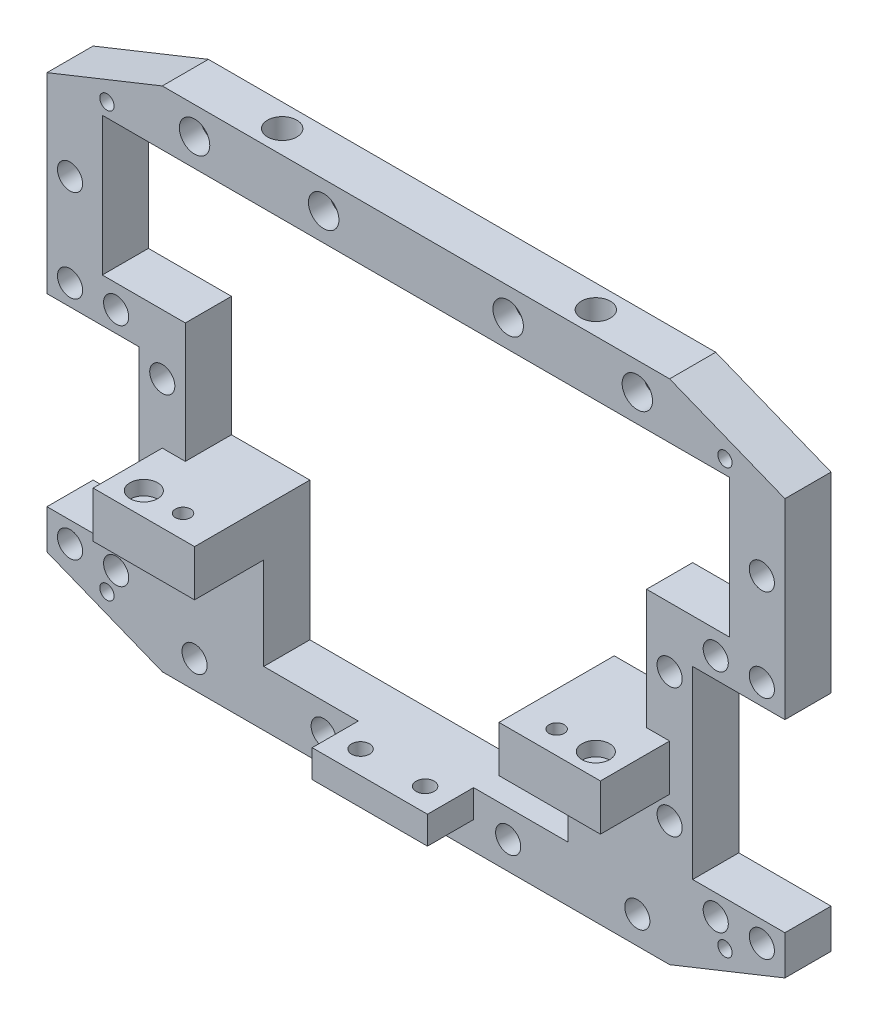
from build123d import *

# Parameters (mm, degrees)
SKETCH1_R                 = 2.725
SKETCH1_R_2               = 2.1
BOSS_EXTRUDE2_DEPTH       = 202.6
SKETCH2_W                 = 182.6
SKETCH2_H                 = 86
CUT_EXTRUDE1_DEPTH        = 161
CUT_EXTRUDE3_START        = 182.6
SKETCH4_R                 = 3
CUT_EXTRUDE3_DEPTH        = 4.5
SKETCH3_W                 = 110
SKETCH3_H                 = 182.6
CUT_EXTRUDE4_DEPTH        = 111
CUT_EXTRUDE5_START        = -12
SKETCH5_W                 = 125
SKETCH5_H                 = 182.6
CUT_EXTRUDE5_DEPTH        = 111
SKETCH6_W                 = 20
SKETCH6_H                 = 40
CUT_EXTRUDE7_DEPTH        = 12
SKETCH8_R                 = 2.725
BOSS_EXTRUDE3_DEPTH       = 10
BOSS_EXTRUDE4_START       = -192.6
SKETCH8_2_R               = 2.725
BOSS_EXTRUDE4_DEPTH       = 10
BOSS_EXTRUDE5_START       = 30
SKETCH9_W                 = 2
SKETCH9_H                 = 10
SKETCH9_W_2               = 15
SKETCH9_H_2               = 5
SKETCH9_R                 = 1.65
BOSS_EXTRUDE5_DEPTH       = 10
SKETCH10_W                = 22
SKETCH10_H                = 10
BOSS_EXTRUDE6_DEPTH       = 20
MIRROR3_START             = 30
MIRROR3_COPY_1_SKETCH_W   = 2
MIRROR3_COPY_1_SKETCH_H   = 10
MIRROR3_COPY_1_SKETCH_W_2 = 15
MIRROR3_COPY_1_SKETCH_H_2 = 5
MIRROR3_COPY_1_SKETCH_R   = 1.65
MIRROR3_COPY_1_DEPTH      = 10
MIRROR3_COPY_2_SKETCH_W   = 22
MIRROR3_COPY_2_SKETCH_H   = 10
MIRROR3_COPY_2_DEPTH      = 20
SKETCH11_R                = 2.25
CUT_EXTRUDE8_DEPTH        = 203.6
SKETCH12_R                = 3
CUT_EXTRUDE9_DEPTH        = 3.1
CUT_EXTRUDE10_DEPTH       = 111
SKETCH14_R                = 1.55
CUT_EXTRUDE11_DEPTH       = 10
SKETCH15_R                = 2.6
CUT_EXTRUDE12_DEPTH       = 5
BOSS_EXTRUDE7_START       = -12
SKETCH16_W                = 25
SKETCH16_H                = 10
SKETCH16_R                = 1.95
BOSS_EXTRUDE7_DEPTH       = 6
SKETCH17_R                = 1.95
CUT_EXTRUDE13_DEPTH       = 5
SKETCH18_R                = 2.725
CUT_EXTRUDE14_DEPTH       = 11
SKETCH19_R                = 3.175
CUT_EXTRUDE15_DEPTH       = 20
SKETCH20_R                = 2.725
CUT_EXTRUDE16_DEPTH       = 20
SKETCH21_R                = 3.3
CUT_EXTRUDE17_DEPTH       = 4.5


with BuildPart() as part:
    # Sketch1 → Boss-Extrude2 (new body)
    with BuildSketch(Plane.XY):
        Polygon((-48.624838984, -50.035732152), (61.375161016, -50.035732152), (86.375161016, -40.035732152), (86.375161016, 49.964267848), (61.375161016, 59.964267848), (-48.624838984, 59.964267848), (-73.624838984, 49.964267848), (-73.624838984, -40.035732152), align=None)
        with Locations((-41.624838984, -44.035732152)):
            Circle(SKETCH1_R, mode=Mode.SUBTRACT)
        with Locations((-68.624838984, -23.035732152)):
            Circle(SKETCH1_R, mode=Mode.SUBTRACT)
        with Locations((-13.624838984, -44.035732152)):
            Circle(SKETCH1_R, mode=Mode.SUBTRACT)
        with Locations((-68.624838984, 4.964267848)):
            Circle(SKETCH1_R, mode=Mode.SUBTRACT)
        with Locations((26.375161016, -44.035732152)):
            Circle(SKETCH1_R, mode=Mode.SUBTRACT)
        with Locations((54.375161016, -44.035732152)):
            Circle(SKETCH1_R, mode=Mode.SUBTRACT)
        with Locations((81.375161016, -23.035732152)):
            Circle(SKETCH1_R, mode=Mode.SUBTRACT)
        Polygon((74.375161016, 47.964267848), (74.375161016, -38.035732152), (13.375161016, -38.035732152), (-0.624838984, -38.035732152), (-61.624838984, -38.035732152), (-61.624838984, 47.964267848), (-7.624838984, 47.964267848), (-0.624838984, 47.964267848), (13.375161016, 47.964267848), (20.375161016, 47.964267848), align=None, mode=Mode.SUBTRACT)
        with Locations((81.375161016, 4.964267848)):
            Circle(SKETCH1_R, mode=Mode.SUBTRACT)
        with Locations((-68.624838984, 32.964267848)):
            Circle(SKETCH1_R, mode=Mode.SUBTRACT)
        with Locations((-41.624838984, 53.964267848)):
            Circle(SKETCH1_R_2, mode=Mode.SUBTRACT)
        with Locations((-13.624838984, 53.964267848)):
            Circle(SKETCH1_R_2, mode=Mode.SUBTRACT)
        with Locations((26.375161016, 53.964267848)):
            Circle(SKETCH1_R_2, mode=Mode.SUBTRACT)
        with Locations((81.375161016, 32.964267848)):
            Circle(SKETCH1_R, mode=Mode.SUBTRACT)
        with Locations((54.375161016, 53.964267848)):
            Circle(SKETCH1_R_2, mode=Mode.SUBTRACT)
    extrude(amount=BOSS_EXTRUDE2_DEPTH)

    # Sketch2 → Cut-Extrude1 (cut, through all)
    with BuildSketch(Plane.ZY.offset(73.624838984)):
        with Locations((101.3, 4.964267848)):
            Rectangle(SKETCH2_W, SKETCH2_H)
    extrude(amount=-CUT_EXTRUDE1_DEPTH, mode=Mode.SUBTRACT)

    # Sketch4 → Cut-Extrude3 (cut)
    with BuildSketch(Plane.XY.offset(10).offset(CUT_EXTRUDE3_START)):
        with Locations((-68.624838984, 32.964267848)):
            Circle(SKETCH4_R)
        with Locations((-68.624838984, 4.964267848)):
            Circle(SKETCH4_R)
        with Locations((-68.624838984, -23.035732152)):
            Circle(SKETCH4_R)
        with Locations((-41.624838984, 53.964267848)):
            Circle(SKETCH4_R)
        with Locations((-13.624838984, 53.964267848)):
            Circle(SKETCH4_R)
        with Locations((26.375161016, 53.964267848)):
            Circle(SKETCH4_R)
        with Locations((54.375161016, 53.964267848)):
            Circle(SKETCH4_R)
        with Locations((81.375161016, 32.964267848)):
            Circle(SKETCH4_R)
        with Locations((81.375161016, 4.964267848)):
            Circle(SKETCH4_R)
        with Locations((81.375161016, -23.035732152)):
            Circle(SKETCH4_R)
        with Locations((54.375161016, -44.035732152)):
            Circle(SKETCH4_R)
        with Locations((26.375161016, -44.035732152)):
            Circle(SKETCH4_R)
        with Locations((-13.624838984, -44.035732152)):
            Circle(SKETCH4_R)
        with Locations((-41.624838984, -44.035732152)):
            Circle(SKETCH4_R)
    extrude(amount=CUT_EXTRUDE3_DEPTH, mode=Mode.SUBTRACT)

    # Sketch3 → Cut-Extrude4 (cut, through all)
    with BuildSketch(Plane(origin=(0, 59.964267848, 0), x_dir=(1, 0, 0), z_dir=(0, 1, 0))):
        with Locations((6.375161016, -101.3)):
            Rectangle(SKETCH3_W, SKETCH3_H)
    extrude(amount=-CUT_EXTRUDE4_DEPTH, mode=Mode.SUBTRACT)

    # Sketch5 → Cut-Extrude5 (cut, through all)
    with BuildSketch(Plane(origin=(0, -38.035732152, 0), x_dir=(1, 0, 0), z_dir=(0, 1, 0)).offset(CUT_EXTRUDE5_START)):
        with Locations((6.375161016, -101.3)):
            Rectangle(SKETCH5_W, SKETCH5_H)
    extrude(amount=CUT_EXTRUDE5_DEPTH, mode=Mode.SUBTRACT)

    # Sketch6 → Cut-Extrude7 (cut)
    with BuildSketch(Plane(origin=(86.375161016, 0, 0), x_dir=(0, 0, -1), z_dir=(1, 0, 0))):
        with Locations((-192.6, -11.535732152)):
            Rectangle(SKETCH6_W, SKETCH6_H)
        with Locations((-10, -11.535732152)):
            Rectangle(SKETCH6_W, SKETCH6_H)
    cut_extrude7 = extrude(amount=-CUT_EXTRUDE7_DEPTH, mode=Mode.SUBTRACT)

    # Sketch8 → Boss-Extrude3 (add)
    with BuildSketch(Plane.XY.offset(202.6)):
        Polygon((66.375161016, 8.464267848), (66.375161016, -31.535732152), (74.375161016, -31.535732152), (74.375161016, -38.035732152), (56.375161016, -38.035732152), (56.375161016, 17.964267848), (74.375161016, 17.964267848), (74.375161016, 8.464267848), align=None)
        with Locations((61.375161016, 4.964267848)):
            Circle(SKETCH8_R, mode=Mode.SUBTRACT)
        with Locations((61.375161016, -23.035732152)):
            Circle(SKETCH8_R, mode=Mode.SUBTRACT)
    boss_extrude3 = extrude(amount=-BOSS_EXTRUDE3_DEPTH)

    # Sketch8_2 → Boss-Extrude4 (add)
    with BuildSketch(Plane.XY.offset(202.6).offset(BOSS_EXTRUDE4_START)):
        Polygon((66.375161016, 8.464267848), (66.375161016, -31.535732152), (74.375161016, -31.535732152), (74.375161016, -38.035732152), (56.375161016, -38.035732152), (56.375161016, 17.964267848), (74.375161016, 17.964267848), (74.375161016, 8.464267848), align=None)
        with Locations((61.375161016, 4.964267848)):
            Circle(SKETCH8_2_R, mode=Mode.SUBTRACT)
        with Locations((61.375161016, -23.035732152)):
            Circle(SKETCH8_2_R, mode=Mode.SUBTRACT)
    boss_extrude4 = extrude(amount=-BOSS_EXTRUDE4_DEPTH)

    # Mirror1: Cut-Extrude7, Boss-Extrude3, Boss-Extrude4 across plane
    add(cut_extrude7.mirror(Plane(origin=(6.375161016, 0, 0), x_dir=(0, 0, 1), z_dir=(1, 0, 0))), mode=Mode.SUBTRACT)
    add(boss_extrude3.mirror(Plane(origin=(6.375161016, 0, 0), x_dir=(0, 0, 1), z_dir=(1, 0, 0))))
    add(boss_extrude4.mirror(Plane(origin=(6.375161016, 0, 0), x_dir=(0, 0, 1), z_dir=(1, 0, 0))))

    # Sketch9 → Boss-Extrude5 (add)
    with BuildSketch(Plane(origin=(0, -38.035732152, 0), x_dir=(1, 0, 0), z_dir=(0, 1, 0)).offset(BOSS_EXTRUDE5_START)):
        Polygon((-48.624838984, -25), (-41.624838984, -25), (-41.624838984, -15), (-41.624838984, -10), (-43.624838984, -10), (-43.624838984, 0), (-48.624838984, 0), align=None)
        with Locations((-42.624838984, -5)):
            Rectangle(SKETCH9_W, SKETCH9_H)
        with Locations((-34.124838984, -5)):
            Rectangle(SKETCH9_W_2, SKETCH9_H)
        with Locations((-34.124838984, -12.5)):
            Rectangle(SKETCH9_W_2, SKETCH9_H_2)
        with Locations((-34.124838984, -20)):
            Rectangle(SKETCH9_W_2, SKETCH9_H)
        with Locations((-34.124838984, -20)):
            Circle(SKETCH9_R, mode=Mode.SUBTRACT)
    boss_extrude5 = extrude(amount=-BOSS_EXTRUDE5_DEPTH)

    # Sketch10 → Boss-Extrude6 (add)
    with BuildSketch(Plane.XZ.offset(18.035732152)):
        with Locations((-37.624838984, 5)):
            Rectangle(SKETCH10_W, SKETCH10_H)
    boss_extrude6 = extrude(amount=BOSS_EXTRUDE6_DEPTH)

    # Mirror2: Boss-Extrude5, Boss-Extrude6 across plane
    add(boss_extrude5.mirror(Plane.XY.offset(101.3)))
    add(boss_extrude6.mirror(Plane.XY.offset(101.3)))

    # Mirror3: Boss-Extrude5, Boss-Extrude6 across plane
    add(boss_extrude5.mirror(Plane(origin=(6.375161016, 0, 0), x_dir=(0, 0, 1), z_dir=(1, 0, 0))))
    add(boss_extrude6.mirror(Plane(origin=(6.375161016, 0, 0), x_dir=(0, 0, 1), z_dir=(1, 0, 0))))

    # Mirror3 copy 1 sketch → Mirror3 copy 1 (add)
    with BuildSketch(Plane(origin=(12.750322031, -38.035732152, 202.6), x_dir=(-1, 0, 0), z_dir=(0, 1, 0)).offset(MIRROR3_START)):
        Polygon((-48.624838984, -25), (-41.624838984, -25), (-41.624838984, -15), (-41.624838984, -10), (-43.624838984, -10), (-43.624838984, 0), (-48.624838984, 0), align=None)
        with Locations((-42.624838984, -5)):
            Rectangle(MIRROR3_COPY_1_SKETCH_W, MIRROR3_COPY_1_SKETCH_H)
        with Locations((-34.124838984, -5)):
            Rectangle(MIRROR3_COPY_1_SKETCH_W_2, MIRROR3_COPY_1_SKETCH_H)
        with Locations((-34.124838984, -12.5)):
            Rectangle(MIRROR3_COPY_1_SKETCH_W_2, MIRROR3_COPY_1_SKETCH_H_2)
        with Locations((-34.124838984, -20)):
            Rectangle(MIRROR3_COPY_1_SKETCH_W_2, MIRROR3_COPY_1_SKETCH_H)
        with Locations((-34.124838984, -20)):
            Circle(MIRROR3_COPY_1_SKETCH_R, mode=Mode.SUBTRACT)
    extrude(amount=-MIRROR3_COPY_1_DEPTH)

    # Mirror3 copy 2 sketch → Mirror3 copy 2 (add)
    with BuildSketch(Plane(origin=(12.750322031, -18.035732152, 202.6), x_dir=(-1, 0, 0), z_dir=(0, -1, 0))):
        with Locations((-37.624838984, 5)):
            Rectangle(MIRROR3_COPY_2_SKETCH_W, MIRROR3_COPY_2_SKETCH_H)
    extrude(amount=MIRROR3_COPY_2_DEPTH)

    # Sketch11 → Cut-Extrude8 (cut, through all)
    with BuildSketch(Plane.XY.offset(202.6)):
        with Locations((-48.624838984, -23.035732152)):
            Circle(SKETCH11_R)
        with Locations((61.375161016, -23.035732152)):
            Circle(SKETCH11_R)
    extrude(amount=-CUT_EXTRUDE8_DEPTH, mode=Mode.SUBTRACT)

    # Sketch12 → Cut-Extrude9 (cut)
    with BuildSketch(Plane(origin=(0, -8.035732152, 0), x_dir=(1, 0, 0), z_dir=(0, 1, 0))):
        with Locations((-42.624838984, -20)):
            Circle(SKETCH12_R)
        with Locations((55.375161016, -20)):
            Circle(SKETCH12_R)
        with Locations((55.375161016, -182.6)):
            Circle(SKETCH12_R)
        with Locations((-42.624838984, -182.6)):
            Circle(SKETCH12_R)
    extrude(amount=-CUT_EXTRUDE9_DEPTH, mode=Mode.SUBTRACT)

    # Sketch13 → Cut-Extrude10 (cut, through all)
    with BuildSketch(Plane(origin=(0, 59.964267848, 0), x_dir=(1, 0, 0), z_dir=(0, 1, 0))):
        Polygon((-52.374838984, -10), (-52.374838984, -41.45964147), (65.444041386, -41.45964147), (65.125161016, -10), (86.375161016, -10), (86.375161016, -202.6), (-73.624838984, -202.6), (-73.624838984, -10), align=None)
    extrude(amount=-CUT_EXTRUDE10_DEPTH, mode=Mode.SUBTRACT)

    # Sketch14 → Cut-Extrude11 (cut)
    with BuildSketch(Plane.XY.offset(10)):
        with Locations((-60.624838984, 50.964267848)):
            Circle(SKETCH14_R)
        with Locations((73.375161016, 50.964267848)):
            Circle(SKETCH14_R)
        with Locations((73.375161016, -41.035732152)):
            Circle(SKETCH14_R)
        with Locations((-60.624838984, -41.035732152)):
            Circle(SKETCH14_R)
    extrude(amount=-CUT_EXTRUDE11_DEPTH, mode=Mode.SUBTRACT)

    # Sketch15 → Cut-Extrude12 (cut)
    with BuildSketch(Plane(origin=(0, 0, 0), x_dir=(-1, 0, 0), z_dir=(0, 0, -1))):
        with Locations((-73.375161016, 50.964267848)):
            Circle(SKETCH15_R)
        with Locations((-73.375161016, -41.035732152)):
            Circle(SKETCH15_R)
        with Locations((60.624838984, -41.035732152)):
            Circle(SKETCH15_R)
        with Locations((60.624838984, 50.964267848)):
            Circle(SKETCH15_R)
    extrude(amount=-CUT_EXTRUDE12_DEPTH, mode=Mode.SUBTRACT)

    # Sketch16 → Boss-Extrude7 (add)
    with BuildSketch(Plane.XZ.offset(50.035732152).offset(BOSS_EXTRUDE7_START)):
        with Locations((6.375161016, 15)):
            Rectangle(SKETCH16_W, SKETCH16_H)
        with Locations((-0.624838984, 15)):
            Circle(SKETCH16_R, mode=Mode.SUBTRACT)
        with Locations((13.375161016, 15)):
            Circle(SKETCH16_R, mode=Mode.SUBTRACT)
    extrude(amount=BOSS_EXTRUDE7_DEPTH)

    # Sketch17 → Cut-Extrude13 (cut)
    with BuildSketch(Plane.XZ.offset(18.035732152)):
        with Locations((-42.624838984, 15)):
            Circle(SKETCH17_R)
        with Locations((45.375161016, 15)):
            Circle(SKETCH17_R)
        with Locations((55.375161016, 15)):
            Circle(SKETCH17_R)
        with Locations((-32.624838984, 15)):
            Circle(SKETCH17_R)
    extrude(amount=-CUT_EXTRUDE13_DEPTH, mode=Mode.SUBTRACT)

    # Sketch18 → Cut-Extrude14 (cut, through all)
    with BuildSketch(Plane.XY.offset(10)):
        with Locations((-68.624838984, 12.964267848)):
            Circle(SKETCH18_R)
        with Locations((-58.624838984, 12.964267848)):
            Circle(SKETCH18_R)
        with Locations((-68.624838984, -36.035732152)):
            Circle(SKETCH18_R)
        with Locations((-58.624838984, -36.035732152)):
            Circle(SKETCH18_R)
    cut_extrude14 = extrude(amount=-CUT_EXTRUDE14_DEPTH, mode=Mode.SUBTRACT)

    # Mirror5: Cut-Extrude14 across plane
    add(cut_extrude14.mirror(Plane(origin=(6.375161016, 59.964267848, 0), x_dir=(0, 0, 1), z_dir=(-1, 0, 0))), mode=Mode.SUBTRACT)

    # Sketch19 → Cut-Extrude15 (cut)
    with BuildSketch(Plane(origin=(0, 59.964267848, 0), x_dir=(1, 0, 0), z_dir=(0, 1, 0))):
        with Locations((-27.624838984, -5)):
            Circle(SKETCH19_R)
        with Locations((40.375161016, -5)):
            Circle(SKETCH19_R)
    extrude(amount=-CUT_EXTRUDE15_DEPTH, mode=Mode.SUBTRACT)

    # Sketch20 → Cut-Extrude16 (cut)
    with BuildSketch(Plane.XY.offset(10)):
        with Locations((-48.624838984, -23.035732152)):
            Circle(SKETCH20_R)
        with Locations((61.375161016, -23.035732152)):
            Circle(SKETCH20_R)
    extrude(amount=-CUT_EXTRUDE16_DEPTH, mode=Mode.SUBTRACT)

    # Sketch21 → Cut-Extrude17 (cut)
    with BuildSketch(Plane.XY.offset(10)):
        with Locations((-13.624838984, 53.964267848)):
            Circle(SKETCH21_R)
        with Locations((-41.624838984, 53.964267848)):
            Circle(SKETCH21_R)
        with Locations((26.375161016, 53.964267848)):
            Circle(SKETCH21_R)
        with Locations((54.375161016, 53.964267848)):
            Circle(SKETCH21_R)
    extrude(amount=-CUT_EXTRUDE17_DEPTH, mode=Mode.SUBTRACT)


solid = part.part
